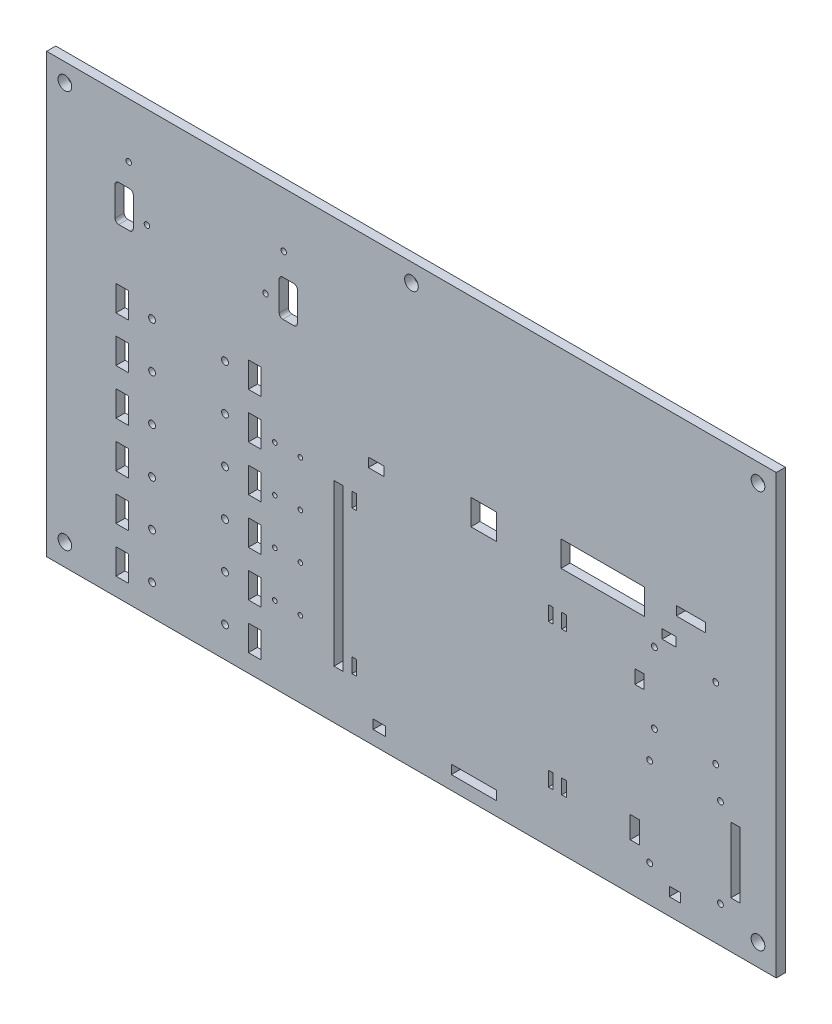
from build123d import *

# Parameters (mm, degrees)
SKETCH1_W            = 508
SKETCH1_H            = 304.8
BOSS_EXTRUDE1_DEPTH  = 6.35
SKETCH2_OUTSIDE_W    = 628.492
SKETCH2_OUTSIDE_H    = 425.292
SKETCH2_OUTSIDE_W_2  = 508
SKETCH2_OUTSIDE_H_2  = 304.8
SKETCH2_OUTSIDE_R    = 2.38125
SKETCH2_OUTSIDE_R_2  = 1.5875
SKETCH2_OUTSIDE_R_3  = 4.7625
SKETCH2_OUTSIDE_R_4  = 2.032
SKETCH2_OUTSIDE_R_5  = 1.89865
SKETCH2_OUTSIDE_W_3  = 8.89
SKETCH2_OUTSIDE_H_3  = 17.78
SKETCH2_OUTSIDE_W_4  = 6.35
SKETCH2_OUTSIDE_H_4  = 9.525
SKETCH2_OUTSIDE_W_5  = 9.525
SKETCH2_OUTSIDE_H_5  = 6.35
SKETCH2_OUTSIDE_W_6  = 8.7376
SKETCH2_OUTSIDE_W_7  = 31.496
SKETCH2_OUTSIDE_H_6  = 112.014
SKETCH2_OUTSIDE_W_8  = 10.922
SKETCH2_OUTSIDE_W_9  = 17.78
SKETCH2_OUTSIDE_W_10 = 3.175
SKETCH2_OUTSIDE_H_7  = 10.16
SKETCH2_OUTSIDE_W_11 = 58.166
SKETCH2_OUTSIDE_W_12 = 20.32
SKETCH2_OUTSIDE_H_8  = 15.24
SKETCH2_OUTSIDE_W_13 = 7.62
SKETCH2_OUTSIDE_H_9  = 45.72
CUT_EXTRUDE1_DEPTH   = 7.62


with BuildPart() as part:
    # Sketch1 → Boss-Extrude1 (new body)
    with BuildSketch(Plane.XY):
        with Locations((4.79245283, -50.693501048)):
            Rectangle(SKETCH1_W, SKETCH1_H)
    extrude(amount=BOSS_EXTRUDE1_DEPTH)

    # Sketch2 outside → Cut-Extrude1 (cut)
    with BuildSketch(Plane.XY.offset(6.35)):
        with Locations((4.792, -50.694)):
            Rectangle(SKETCH2_OUTSIDE_W, SKETCH2_OUTSIDE_H)
        with Locations((4.79245283, -50.693501048)):
            Rectangle(SKETCH2_OUTSIDE_W_2, SKETCH2_OUTSIDE_H_2, mode=Mode.SUBTRACT)
        with Locations((-175.80154717, -181.757501048)):
            Circle(SKETCH2_OUTSIDE_R)
        with Locations((-125.00154717, -181.757501048)):
            Circle(SKETCH2_OUTSIDE_R)
        with Locations((-175.80154717, -150.007501048)):
            Circle(SKETCH2_OUTSIDE_R)
        with Locations((-125.00154717, -150.007501048)):
            Circle(SKETCH2_OUTSIDE_R)
        with Locations((-175.80154717, -118.257501048)):
            Circle(SKETCH2_OUTSIDE_R)
        with Locations((-125.00154717, -118.257501048)):
            Circle(SKETCH2_OUTSIDE_R)
        with Locations((-175.80154717, -86.507501048)):
            Circle(SKETCH2_OUTSIDE_R)
        with Locations((-125.00154717, -86.507501048)):
            Circle(SKETCH2_OUTSIDE_R)
        with Locations((-175.80154717, -54.757501048)):
            Circle(SKETCH2_OUTSIDE_R)
        with Locations((-125.00154717, -54.757501048)):
            Circle(SKETCH2_OUTSIDE_R)
        with Locations((-90.33054717, -150.007501048)):
            Circle(SKETCH2_OUTSIDE_R_2)
        with Locations((-72.55054717, -150.007501048)):
            Circle(SKETCH2_OUTSIDE_R_2)
        with Locations((-236.50754717, -187.853501048)):
            Circle(SKETCH2_OUTSIDE_R_3)
        with Locations((-236.50754717, 89.006498952)):
            Circle(SKETCH2_OUTSIDE_R_3)
        with Locations((4.79245283, 89.006498952)):
            Circle(SKETCH2_OUTSIDE_R_3)
        with Locations((246.09245283, 89.006498952)):
            Circle(SKETCH2_OUTSIDE_R_3)
        with Locations((246.09245283, -187.853501048)):
            Circle(SKETCH2_OUTSIDE_R_3)
        with Locations((-175.80154717, -23.007501048)):
            Circle(SKETCH2_OUTSIDE_R)
        with Locations((-125.00154717, -23.007501048)):
            Circle(SKETCH2_OUTSIDE_R)
        with Locations((-72.55054717, -118.257501048)):
            Circle(SKETCH2_OUTSIDE_R_2)
        with Locations((-90.33054717, -118.257501048)):
            Circle(SKETCH2_OUTSIDE_R_2)
        with Locations((-72.55054717, -86.507501048)):
            Circle(SKETCH2_OUTSIDE_R_2)
        with Locations((-90.33054717, -86.507501048)):
            Circle(SKETCH2_OUTSIDE_R_2)
        with Locations((-72.55054717, -54.757501048)):
            Circle(SKETCH2_OUTSIDE_R_2)
        with Locations((-90.33054717, -54.757501048)):
            Circle(SKETCH2_OUTSIDE_R_2)
        with Locations((216.62845283, -45.867501048)):
            Circle(SKETCH2_OUTSIDE_R_4)
        with Locations((216.62845283, -95.143501048)):
            Circle(SKETCH2_OUTSIDE_R_4)
        with Locations((173.95645283, -95.143501048)):
            Circle(SKETCH2_OUTSIDE_R_4)
        with Locations((173.95645283, -45.867501048)):
            Circle(SKETCH2_OUTSIDE_R_4)
        with Locations((219.93045283, -177.693501048)):
            Circle(SKETCH2_OUTSIDE_R_4)
        with Locations((170.65445283, -177.693501048)):
            Circle(SKETCH2_OUTSIDE_R_4)
        with Locations((170.65445283, -115.971501048)):
            Circle(SKETCH2_OUTSIDE_R_4)
        with Locations((219.93045283, -115.971501048)):
            Circle(SKETCH2_OUTSIDE_R_4)
        with Locations((-192.05754717, 63.606498952)):
            Circle(SKETCH2_OUTSIDE_R_5)
        with Locations((-84.10754717, 63.606498952)):
            Circle(SKETCH2_OUTSIDE_R_5)
        with Locations((-179.35754717, 31.856498952)):
            Circle(SKETCH2_OUTSIDE_R_5)
        with Locations((-96.80754717, 31.856498952)):
            Circle(SKETCH2_OUTSIDE_R_5)
        with Locations((-196.50254717, -181.757501048)):
            Rectangle(SKETCH2_OUTSIDE_W_3, SKETCH2_OUTSIDE_H_3)
        with Locations((-196.50254717, -150.007501048)):
            Rectangle(SKETCH2_OUTSIDE_W_3, SKETCH2_OUTSIDE_H_3)
        with Locations((-196.50254717, -118.257501048)):
            Rectangle(SKETCH2_OUTSIDE_W_3, SKETCH2_OUTSIDE_H_3)
        with Locations((-196.50254717, -86.507501048)):
            Rectangle(SKETCH2_OUTSIDE_W_3, SKETCH2_OUTSIDE_H_3)
        with Locations((-196.50254717, -54.757501048)):
            Rectangle(SKETCH2_OUTSIDE_W_3, SKETCH2_OUTSIDE_H_3)
        with Locations((-196.50254717, -23.007501048)):
            Rectangle(SKETCH2_OUTSIDE_W_3, SKETCH2_OUTSIDE_H_3)
        with Locations((-104.30054717, -181.757501048)):
            Rectangle(SKETCH2_OUTSIDE_W_3, SKETCH2_OUTSIDE_H_3)
        with Locations((-104.30054717, -150.007501048)):
            Rectangle(SKETCH2_OUTSIDE_W_3, SKETCH2_OUTSIDE_H_3)
        with Locations((-104.30054717, -118.257501048)):
            Rectangle(SKETCH2_OUTSIDE_W_3, SKETCH2_OUTSIDE_H_3)
        with Locations((-104.30054717, -86.507501048)):
            Rectangle(SKETCH2_OUTSIDE_W_3, SKETCH2_OUTSIDE_H_3)
        with Locations((-104.30054717, -54.757501048)):
            Rectangle(SKETCH2_OUTSIDE_W_3, SKETCH2_OUTSIDE_H_3)
        with Locations((-104.30054717, -23.007501048)):
            Rectangle(SKETCH2_OUTSIDE_W_3, SKETCH2_OUTSIDE_H_3)
        with Locations((163.54245283, -70.505501048)):
            Rectangle(SKETCH2_OUTSIDE_W_4, SKETCH2_OUTSIDE_H_4)
        with Locations((184.11645283, -35.326501048)):
            Rectangle(SKETCH2_OUTSIDE_W_5, SKETCH2_OUTSIDE_H_5)
        with Locations((-17.50874717, -190.393501048)):
            Rectangle(SKETCH2_OUTSIDE_W_6, SKETCH2_OUTSIDE_H_5)
        with Locations((48.32805283, -190.393501048)):
            Rectangle(SKETCH2_OUTSIDE_W_7, SKETCH2_OUTSIDE_H_5)
        with Locations((-46.00754717, -113.050501048)):
            Rectangle(SKETCH2_OUTSIDE_W_4, SKETCH2_OUTSIDE_H_6)
        with Locations((-19.71854717, -34.132701048)):
            Rectangle(SKETCH2_OUTSIDE_W_8, SKETCH2_OUTSIDE_H_5)
        with Locations((55.08445283, -28.417701048)):
            Rectangle(SKETCH2_OUTSIDE_W_9, SKETCH2_OUTSIDE_H_3)
        with Locations((-35.02204717, -162.199501048)):
            Rectangle(SKETCH2_OUTSIDE_W_10, SKETCH2_OUTSIDE_H_7)
        with Locations((-35.02204717, -62.326701048)):
            Rectangle(SKETCH2_OUTSIDE_W_10, SKETCH2_OUTSIDE_H_7)
        with Locations((101.75695283, -162.199501048)):
            Rectangle(SKETCH2_OUTSIDE_W_10, SKETCH2_OUTSIDE_H_7)
        with Locations((101.75695283, -62.326701048)):
            Rectangle(SKETCH2_OUTSIDE_W_10, SKETCH2_OUTSIDE_H_7)
        with Locations((111.02795283, -162.199501048)):
            Rectangle(SKETCH2_OUTSIDE_W_10, SKETCH2_OUTSIDE_H_7)
        with Locations((111.02795283, -62.326701048)):
            Rectangle(SKETCH2_OUTSIDE_W_10, SKETCH2_OUTSIDE_H_7)
        with Locations((138.01545283, -22.118501048)):
            Rectangle(SKETCH2_OUTSIDE_W_11, SKETCH2_OUTSIDE_H_3)
        with Locations((199.35645283, -16.403501048)):
            Rectangle(SKETCH2_OUTSIDE_W_12, SKETCH2_OUTSIDE_H_5)
        with Locations((160.24045283, -162.961501048)):
            Rectangle(SKETCH2_OUTSIDE_W_4, SKETCH2_OUTSIDE_H_8)
        with Locations((188.18045283, -188.107501048)):
            Rectangle(SKETCH2_OUTSIDE_W_13, SKETCH2_OUTSIDE_H_5)
        with Locations((230.34445283, -147.721501048)):
            Rectangle(SKETCH2_OUTSIDE_W_4, SKETCH2_OUTSIDE_H_9)
        with BuildLine():
            Line((-188.88254717, 24.871498952), (-188.88254717, 45.191498952))
            ThreePointArc((-188.88254717, 45.191498952), (-189.626495946, 46.987550176), (-191.42254717, 47.731498952))
            Line((-191.42254717, 47.731498952), (-199.04254717, 47.731498952))
            ThreePointArc((-199.04254717, 47.731498952), (-200.838598394, 46.987550176), (-201.58254717, 45.191498952))
            Line((-201.58254717, 45.191498952), (-201.58254717, 24.871498952))
            ThreePointArc((-201.58254717, 24.871498952), (-200.838598394, 23.075447728), (-199.04254717, 22.331498952))
            Line((-199.04254717, 22.331498952), (-191.42254717, 22.331498952))
            ThreePointArc((-191.42254717, 22.331498952), (-189.626495946, 23.075447728), (-188.88254717, 24.871498952))
        make_face()
        with BuildLine():
            Line((-84.74254717, 47.731498952), (-77.12254717, 47.731498952))
            ThreePointArc((-77.12254717, 47.731498952), (-75.326495946, 46.987550176), (-74.58254717, 45.191498952))
            Line((-74.58254717, 45.191498952), (-74.58254717, 24.871498952))
            ThreePointArc((-74.58254717, 24.871498952), (-75.326495946, 23.075447728), (-77.12254717, 22.331498952))
            Line((-77.12254717, 22.331498952), (-84.74254717, 22.331498952))
            ThreePointArc((-84.74254717, 22.331498952), (-86.538598394, 23.075447728), (-87.28254717, 24.871498952))
            Line((-87.28254717, 24.871498952), (-87.28254717, 45.191498952))
            ThreePointArc((-87.28254717, 45.191498952), (-86.538598394, 46.987550176), (-84.74254717, 47.731498952))
        make_face()
    extrude(amount=-CUT_EXTRUDE1_DEPTH, mode=Mode.SUBTRACT)


solid = part.part
